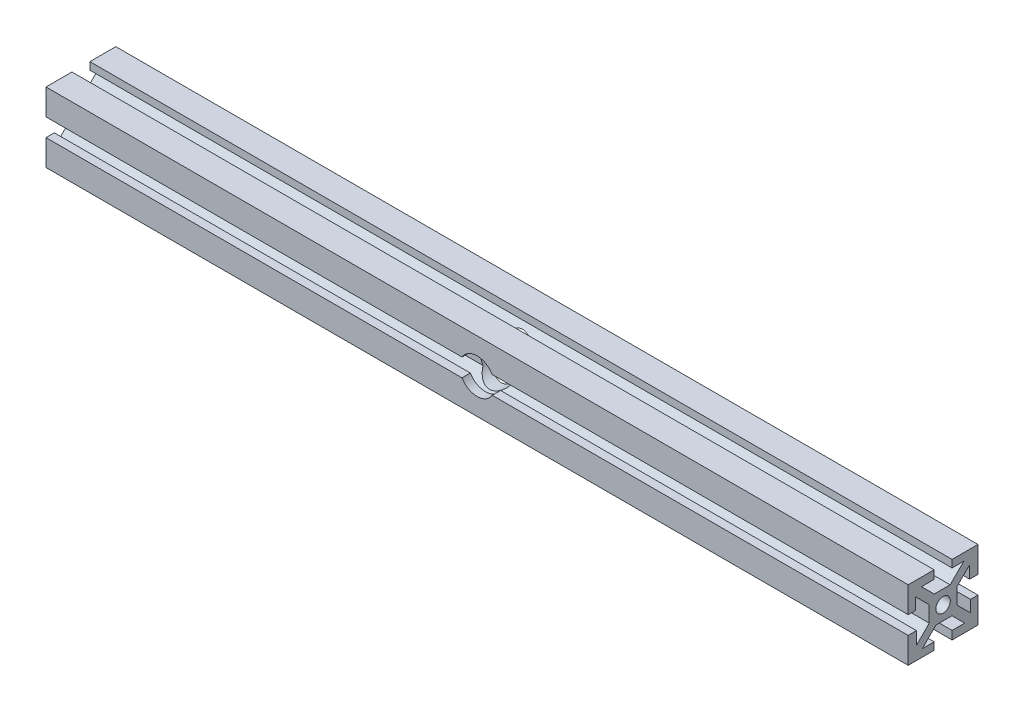
from build123d import *

# Parameters (mm, degrees)
SKETCH1_R           = 2.605
BOSS_EXTRUDE1_DEPTH = 311.15
CIRPATTERN1_COUNT   = 4
SKETCH2_R           = 6.35
CUT_EXTRUDE1_DEPTH  = 30


with BuildPart() as part:
    # Sketch1 → Boss-Extrude1 (new body)
    with BuildSketch(Plane(origin=(0, 0, 0), x_dir=(0, 0, -1), z_dir=(1, 0, 0))):
        Polygon((5, -5), (5, 3.203948776), (9.596194078, 7.800142853), (9.596194078, 3.24), (12.596194078, 3.24), (12.596194078, 12.596194078), (3.24, 12.596194078), (3.24, 9.921463197), (7.474873734, 9.921463197), (2.553410537, 5), (-5, 5), (-5, -5), align=None)
        Circle(SKETCH1_R, mode=Mode.SUBTRACT)
    boss_extrude1 = extrude(amount=BOSS_EXTRUDE1_DEPTH)

    # CirPattern1: Boss-Extrude1 ×4 about axis
    cirpattern1_axis = Axis((0, 0, 0), (1, 0, 0))
    for i in range(1, CIRPATTERN1_COUNT):
        add(boss_extrude1.rotate(cirpattern1_axis, i * 360 / CIRPATTERN1_COUNT))

    # Sketch2 → Cut-Extrude1 (cut)
    with BuildSketch(Plane.XY.offset(12.596194078)):
        with Locations((155.575, 0)):
            Circle(SKETCH2_R)
    extrude(amount=-CUT_EXTRUDE1_DEPTH, mode=Mode.SUBTRACT)


solid = part.part
